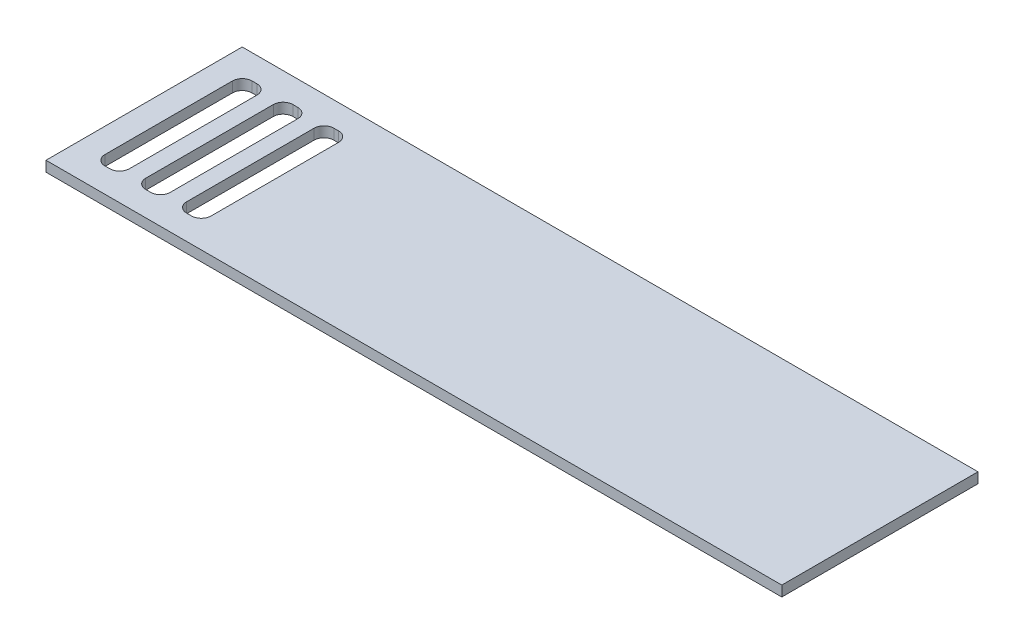
from build123d import *

# Parameters (mm, degrees)
SKETCH1_W               = 450
SKETCH1_H               = 120
BOSS_EXTRUDE1_DEPTH     = 6.35
SKETCH2_W               = 15
SKETCH2_H               = 90
CUT_EXTRUDE1_DEPTH      = 1
CUT_EXTRUDE1_DEPTH_BACK = 7.35
FILLET1_R               = 6


with BuildPart() as part:
    # Sketch1 → Boss-Extrude1 (new body)
    with BuildSketch(Plane(origin=(0, 0, 0), x_dir=(1, 0, 0), z_dir=(0, 1, 0))):
        with Locations((225, 60)):
            Rectangle(SKETCH1_W, SKETCH1_H)
    extrude(amount=BOSS_EXTRUDE1_DEPTH)

    # Sketch2 → Cut-Extrude1 (cut, two sides)
    with BuildSketch(Plane(origin=(0, 6.35, 0), x_dir=(1, 0, 0), z_dir=(0, 1, 0))) as cut_extrude1_sk:
        with Locations((22.5, 60)):
            Rectangle(SKETCH2_W, SKETCH2_H)
        with Locations((47.5, 60)):
            Rectangle(SKETCH2_W, SKETCH2_H)
        with Locations((72.5, 60)):
            Rectangle(SKETCH2_W, SKETCH2_H)
    extrude(amount=CUT_EXTRUDE1_DEPTH, mode=Mode.SUBTRACT)
    extrude(cut_extrude1_sk.sketch, amount=-CUT_EXTRUDE1_DEPTH_BACK, mode=Mode.SUBTRACT)

    # Fillet1
    fillet1_edges = [part.edges().sort_by_distance(p)[0] for p in [
        (15, 3.175, -105),
        (30, 3.175, -105),
        (30, 3.175, -15),
        (15, 3.175, -15),
        (65, 3.175, -105),
        (80, 3.175, -105),
        (80, 3.175, -15),
        (65, 3.175, -15),
        (40, 3.175, -15),
        (40, 3.175, -105),
        (55, 3.175, -105),
        (55, 3.175, -15),
    ]]
    fillet(fillet1_edges, radius=FILLET1_R)


solid = part.part
